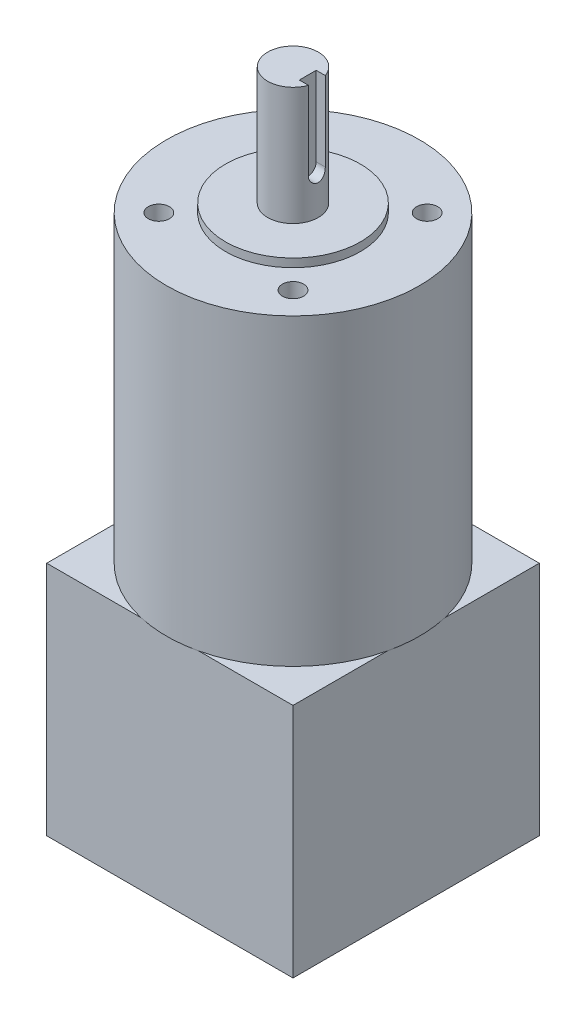
from build123d import *

# Parameters (mm, degrees)
SKETCH1_W           = 58.42
SKETCH1_H           = 58.42
BOSS_EXTRUDE1_DEPTH = 56
SKETCH2_R           = 30
BOSS_EXTRUDE2_DEPTH = 72
SKETCH3_R           = 6
BOSS_EXTRUDE3_DEPTH = 30
SKETCH4_R           = 2.5
CUT_EXTRUDE1_DEPTH  = 25.4
SKETCH5_W           = 2.5
SKETCH5_H           = 4
CUT_EXTRUDE2_DEPTH  = 18.8
SKETCH6_R           = 16
BOSS_EXTRUDE4_DEPTH = 2
CUT_EXTRUDE3_REACH  = 28.5


with BuildPart() as part:
    # Sketch1 → Boss-Extrude1 (new body)
    with BuildSketch(Plane(origin=(0, 0, 0), x_dir=(1, 0, 0), z_dir=(0, 1, 0))):
        Rectangle(SKETCH1_W, SKETCH1_H)
    extrude(amount=BOSS_EXTRUDE1_DEPTH)

    # Sketch2 → Boss-Extrude2 (add)
    with BuildSketch(Plane(origin=(0, 56, 0), x_dir=(1, 0, 0), z_dir=(0, 1, 0))):
        Circle(SKETCH2_R)
    extrude(amount=BOSS_EXTRUDE2_DEPTH)

    # Sketch3 → Boss-Extrude3 (add)
    with BuildSketch(Plane(origin=(0, 128, 0), x_dir=(1, 0, 0), z_dir=(0, 1, 0))):
        Circle(SKETCH3_R)
    extrude(amount=BOSS_EXTRUDE3_DEPTH)

    # Sketch4 → Cut-Extrude1 (cut)
    with BuildSketch(Plane(origin=(0, 128, 0), x_dir=(1, 0, 0), z_dir=(0, 1, 0))):
        with Locations((-15.909902577, 15.909902577)):
            Circle(SKETCH4_R)
        with Locations((15.909902577, 15.909902577)):
            Circle(SKETCH4_R)
        with Locations((15.909902577, -15.909902577)):
            Circle(SKETCH4_R)
        with Locations((-15.909902577, -15.909902577)):
            Circle(SKETCH4_R)
    extrude(amount=-CUT_EXTRUDE1_DEPTH, mode=Mode.SUBTRACT)

    # Sketch5 → Cut-Extrude2 (cut)
    with BuildSketch(Plane(origin=(0, 158, 0), x_dir=(1, 0, 0), z_dir=(0, 1, 0))):
        with Locations((4.75, 0)):
            Rectangle(SKETCH5_W, SKETCH5_H)
    extrude(amount=-CUT_EXTRUDE2_DEPTH, mode=Mode.SUBTRACT)

    # Sketch6 → Boss-Extrude4 (add)
    with BuildSketch(Plane(origin=(0, 128, 0), x_dir=(1, 0, 0), z_dir=(0, 1, 0))):
        Circle(SKETCH6_R)
    extrude(amount=BOSS_EXTRUDE4_DEPTH)

    # Sketch7 → Cut-Extrude3 (cut, up to next)
    with BuildSketch(Plane(origin=(3.5, 0, 0), x_dir=(0, 0, -1), z_dir=(1, 0, 0)), mode=Mode.PRIVATE) as cut_extrude3_sk1:
        with BuildLine():
            Line((2, 139.2), (-2, 139.2))
            ThreePointArc((-2, 139.2), (0, 137.2), (2, 139.2))
        make_face()
    cut_extrude3_tool1 = extrude(cut_extrude3_sk1.sketch, amount=CUT_EXTRUDE3_REACH, mode=Mode.PRIVATE) & part.part
    add(cut_extrude3_tool1.solids().sort_by_distance((3.5, 138.351174, 0))[0], mode=Mode.SUBTRACT)


solid = part.part
